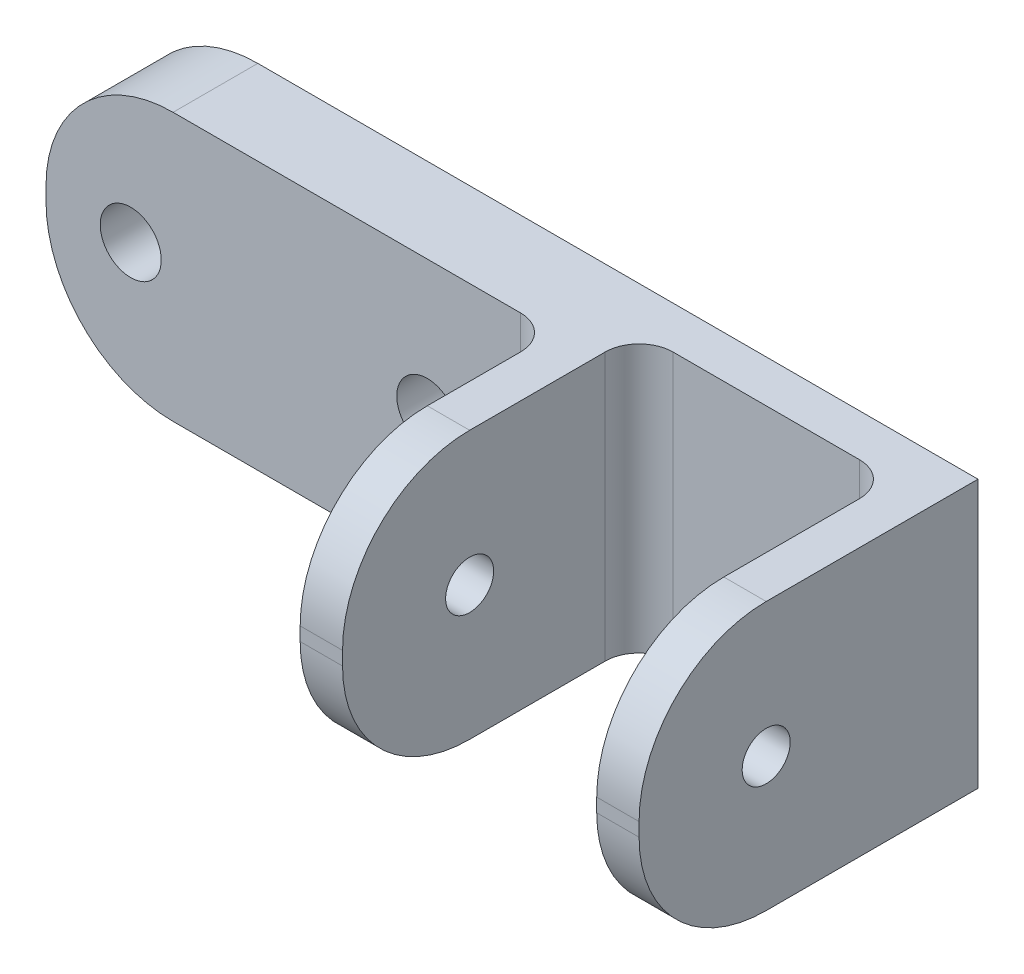
from build123d import *

# Parameters (mm, degrees)
SKETCH1_W               = 63.5
SKETCH1_H               = 20.066
BOSS_EXTRUDE1_DEPTH     = 6.35
SKETCH2_W               = 25.4
SKETCH2_H               = 20.066
BOSS_EXTRUDE2_DEPTH     = 3.175
SKETCH4_W               = 3.175
SKETCH4_H               = 20.066
BOSS_EXTRUDE3_DEPTH     = 19.05
SKETCH3_R               = 1.8
CUT_EXTRUDE1_DEPTH      = 61.325
CUT_EXTRUDE1_DEPTH_BACK = 4.175
SKETCH5_R               = 2.286
CUT_EXTRUDE2_DEPTH      = 7.35
SKETCH6_W               = 19.05
SKETCH6_H               = 20.066
CUT_EXTRUDE3_DEPTH      = 3.175
FILLET1_R               = 2.54
FILLET2_R               = 9.525


with BuildPart() as part:
    # Sketch1 → Boss-Extrude1 (new body)
    with BuildSketch(Plane.XY):
        Rectangle(SKETCH1_W, SKETCH1_H)
    extrude(amount=BOSS_EXTRUDE1_DEPTH)

    # Sketch2 → Boss-Extrude2 (add)
    with BuildSketch(Plane(origin=(31.75, 0, 0), x_dir=(0, 0, -1), z_dir=(1, 0, 0))):
        with Locations((-12.7, 0)):
            Rectangle(SKETCH2_W, SKETCH2_H)
    extrude(amount=-BOSS_EXTRUDE2_DEPTH)

    # Sketch4 → Boss-Extrude3 (add)
    with BuildSketch(Plane.XY.offset(6.35)):
        with Locations((7.9375, 0)):
            Rectangle(SKETCH4_W, SKETCH4_H)
    extrude(amount=BOSS_EXTRUDE3_DEPTH)

    # Sketch3 → Cut-Extrude1 (cut, two sides)
    with BuildSketch(Plane.ZY.offset(-28.575)) as cut_extrude1_sk:
        with Locations((15.875, 0)):
            Circle(SKETCH3_R)
    extrude(amount=CUT_EXTRUDE1_DEPTH, mode=Mode.SUBTRACT)
    extrude(cut_extrude1_sk.sketch, amount=-CUT_EXTRUDE1_DEPTH_BACK, mode=Mode.SUBTRACT)

    # Sketch5 → Cut-Extrude2 (cut, through all)
    with BuildSketch(Plane.XY.offset(6.35)):
        with Locations((-3.175, 0)):
            Circle(SKETCH5_R)
        with Locations((-25.4, 0)):
            Circle(SKETCH5_R)
    extrude(amount=-CUT_EXTRUDE2_DEPTH, mode=Mode.SUBTRACT)

    # Sketch6 → Cut-Extrude3 (cut)
    with BuildSketch(Plane.XY.offset(6.35)):
        with Locations((19.05, 0)):
            Rectangle(SKETCH6_W, SKETCH6_H)
    extrude(amount=-CUT_EXTRUDE3_DEPTH, mode=Mode.SUBTRACT)

    # Fillet1
    fillet1_edges = [part.edges().sort_by_distance(p)[0] for p in [
        (6.35, 0, 6.35),
        (28.575, 0, 3.175),
        (9.525, 0, 3.175),
    ]]
    fillet(fillet1_edges, radius=FILLET1_R)

    # Fillet2
    fillet2_edges = [part.edges().sort_by_distance(p)[0] for p in [
        (30.1625, 10.033, 25.4),
        (30.1625, -10.033, 25.4),
        (7.9375, -10.033, 25.4),
        (7.9375, 10.033, 25.4),
        (-31.75, -10.033, 3.175),
        (-31.75, 10.033, 3.175),
    ]]
    fillet(fillet2_edges, radius=FILLET2_R)


solid = part.part
